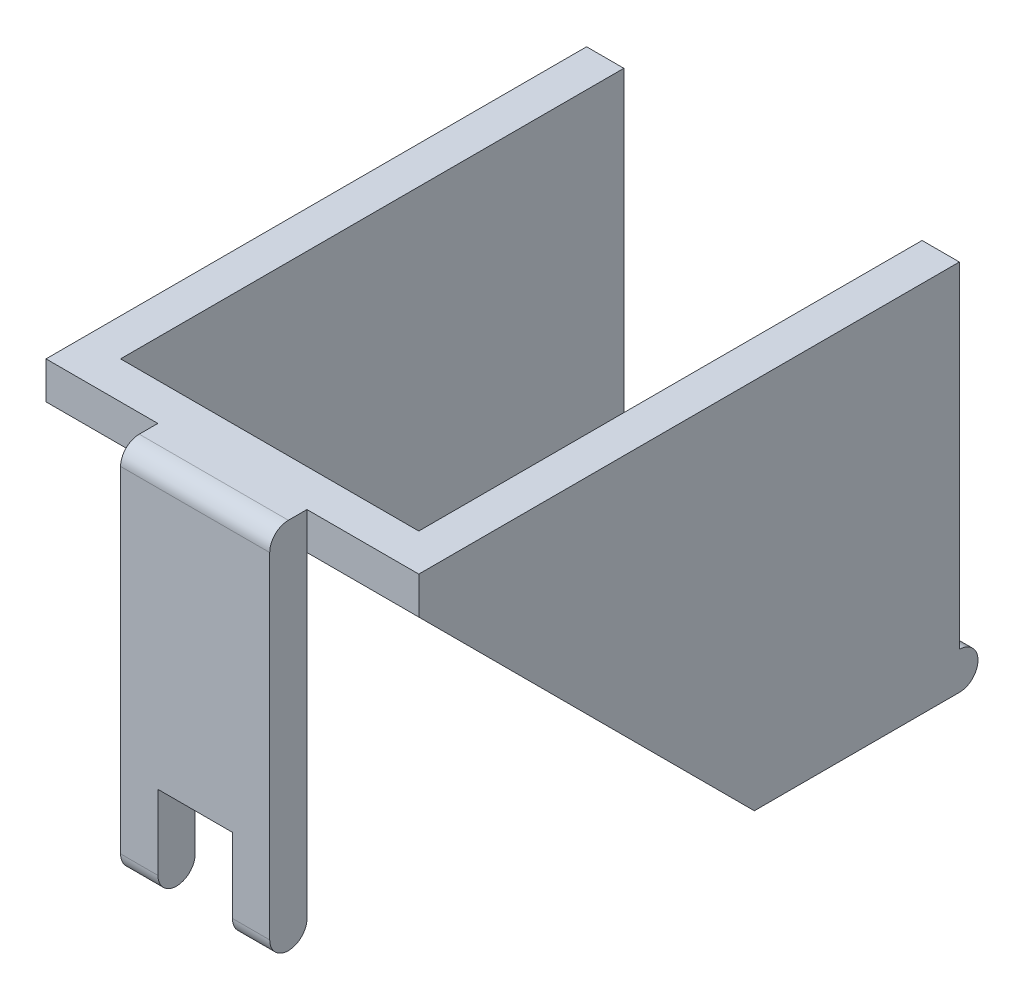
from build123d import *

# Parameters (mm, degrees)
EXTRUDE_3_DEPTH     = 20
SKETCH_4_W          = 6
SKETCH_4_H          = 1.997420006
CUT_EXTRUDE_1_DEPTH = 20
EXTRUDE_4_DEPTH     = 8
SKETCH_6_R          = 1
EXTRUDE_5_DEPTH     = 20
SKETCH_7_W          = 16
SKETCH_7_H          = 28.677583324
CUT_EXTRUDE_3_DEPTH = 18
SKETCH_8_W          = 4
SKETCH_8_H          = 6.365219316
CUT_EXTRUDE_4_DEPTH = 10
SKETCH_9_W          = 8
SKETCH_9_H          = 4
CUT_EXTRUDE_5_DEPTH = 10


with BuildPart() as part:
    # 草图3 → 凸台-拉伸3 (new body)
    with BuildSketch(Plane(origin=(0, 0, 0), x_dir=(0, 0, -1), z_dir=(1, 0, 0))):
        with BuildLine():
            Line((-14.292893219, 8.292893219), (4, -10))
            Line((4, -10), (15, -10))
            Line((15, -10), (15, 10))
            Line((15, 10), (-15, 10))
            ThreePointArc((-15, 10), (-15.923879533, 8.617316568), (-14.292893219, 8.292893219))
        make_face()
    extrude(amount=EXTRUDE_3_DEPTH)

    # 草图4 → 切除-拉伸1 (cut)
    with BuildSketch(Plane(origin=(0, 10, 0), x_dir=(1, 0, 0), z_dir=(0, 1, 0))):
        with Locations((3, -15.001289997)):
            Rectangle(SKETCH_4_W, SKETCH_4_H)
        with Locations((17, -15.001289997)):
            Rectangle(SKETCH_4_W, SKETCH_4_H)
    extrude(amount=-CUT_EXTRUDE_1_DEPTH, mode=Mode.SUBTRACT)

    # 草图5 → 凸台-拉伸4 (add)
    with BuildSketch(Plane(origin=(14, 0, 0), x_dir=(0, 0, -1), z_dir=(1, 0, 0))):
        with BuildLine():
            Line((-14, 9), (-14, -9))
            ThreePointArc((-14, -9), (-15, -10), (-16, -9))
            Line((-16, -9), (-16, 9))
            ThreePointArc((-16, 9), (-15, 10), (-14, 9))
        make_face()
    extrude(amount=-EXTRUDE_4_DEPTH)

    # 草图6 → 凸台-拉伸5 (add)
    with BuildSketch(Plane(origin=(20, 0, 0), x_dir=(0, 0, -1), z_dir=(1, 0, 0))):
        with Locations((15, -9)):
            Circle(SKETCH_6_R)
    extrude(amount=-EXTRUDE_5_DEPTH)

    # 草图7 → 切除-拉伸3 (cut)
    with BuildSketch(Plane(origin=(0, 10, 0), x_dir=(1, 0, 0), z_dir=(0, 1, 0))):
        with Locations((10, 2.336211668)):
            Rectangle(SKETCH_7_W, SKETCH_7_H)
    extrude(amount=-CUT_EXTRUDE_3_DEPTH, mode=Mode.SUBTRACT)

    # 草图8 → 切除-拉伸4 (cut)
    with BuildSketch(Plane.XY.offset(16)):
        with Locations((10, -8.182609658)):
            Rectangle(SKETCH_8_W, SKETCH_8_H)
    extrude(amount=-CUT_EXTRUDE_4_DEPTH, mode=Mode.SUBTRACT)

    # 草图9 → 切除-拉伸5 (cut)
    with BuildSketch(Plane(origin=(0, -8, 0), x_dir=(1, 0, 0), z_dir=(0, 1, 0))):
        with Locations((10, 14)):
            Rectangle(SKETCH_9_W, SKETCH_9_H)
    extrude(amount=-CUT_EXTRUDE_5_DEPTH, mode=Mode.SUBTRACT)


solid = part.part
